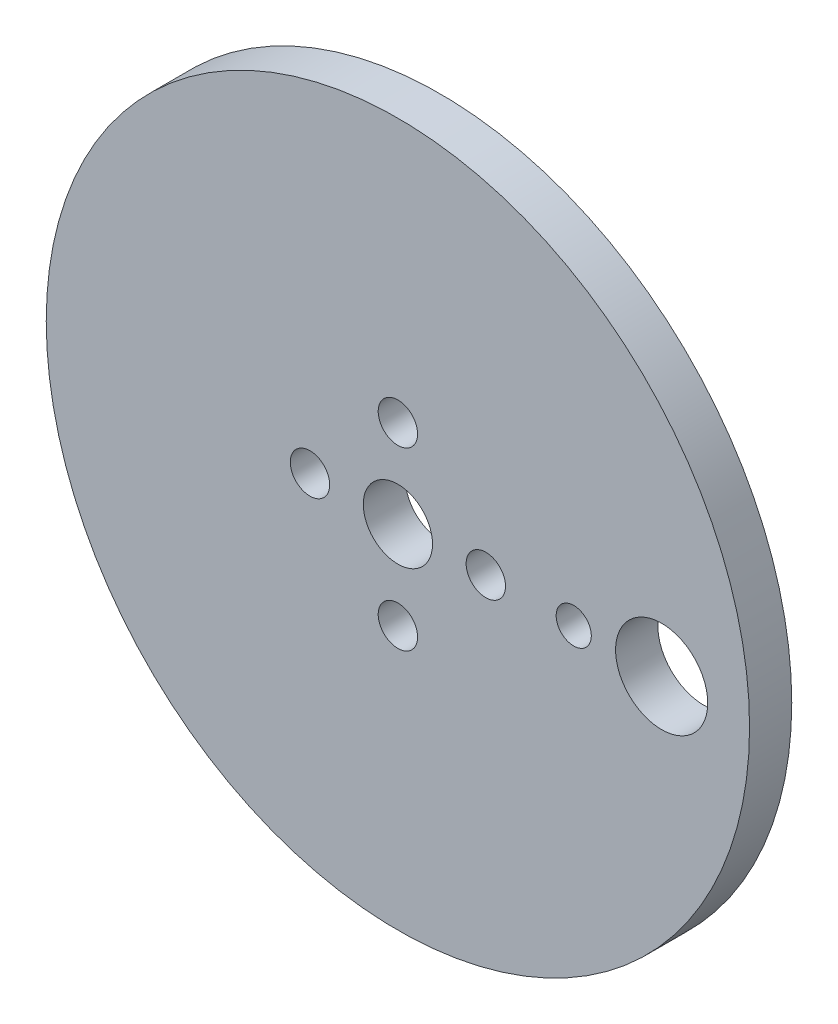
from build123d import *

# Parameters (mm, degrees)
SKETCH1_R           = 25.4
SKETCH1_R_2         = 1.4224
SKETCH1_R_3         = 2.5
SKETCH1_R_4         = 3.3274
SKETCH1_R_5         = 1.27
BOSS_EXTRUDE1_DEPTH = 3.048


with BuildPart() as part:
    # Sketch1 → Boss-Extrude1 (new body)
    with BuildSketch(Plane.XY):
        Circle(SKETCH1_R)
        with Locations((0, 6.35)):
            Circle(SKETCH1_R_2, mode=Mode.SUBTRACT)
        with Locations((6.35, 0)):
            Circle(SKETCH1_R_2, mode=Mode.SUBTRACT)
        with Locations((0, -6.35)):
            Circle(SKETCH1_R_2, mode=Mode.SUBTRACT)
        with Locations((-6.35, 0)):
            Circle(SKETCH1_R_2, mode=Mode.SUBTRACT)
        Circle(SKETCH1_R_3, mode=Mode.SUBTRACT)
        with Locations((19.05, 0)):
            Circle(SKETCH1_R_4, mode=Mode.SUBTRACT)
        with Locations((12.7, 0)):
            Circle(SKETCH1_R_5, mode=Mode.SUBTRACT)
    extrude(amount=BOSS_EXTRUDE1_DEPTH)


solid = part.part
